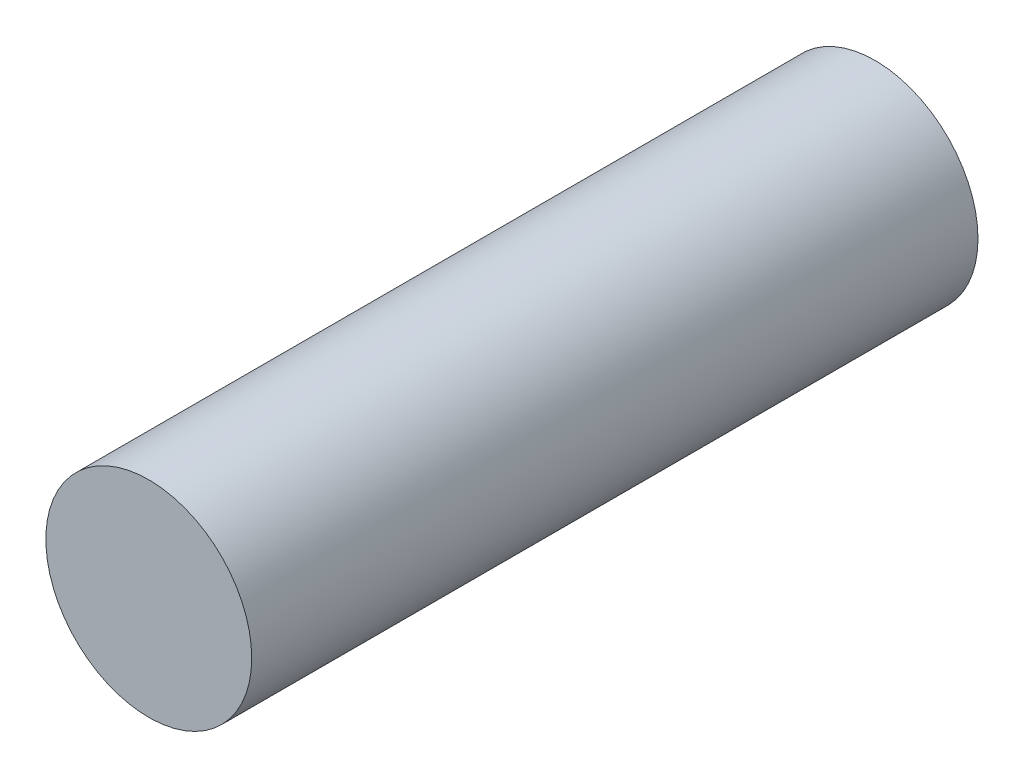
from build123d import *

# Parameters (mm, degrees)
SKETCH1_R           = 7.135
BOSS_EXTRUDE1_DEPTH = 50.34


with BuildPart() as part:
    # Sketch1 → Boss-Extrude1 (new body)
    with BuildSketch(Plane.XY):
        Circle(SKETCH1_R)
    extrude(amount=BOSS_EXTRUDE1_DEPTH)


solid = part.part
